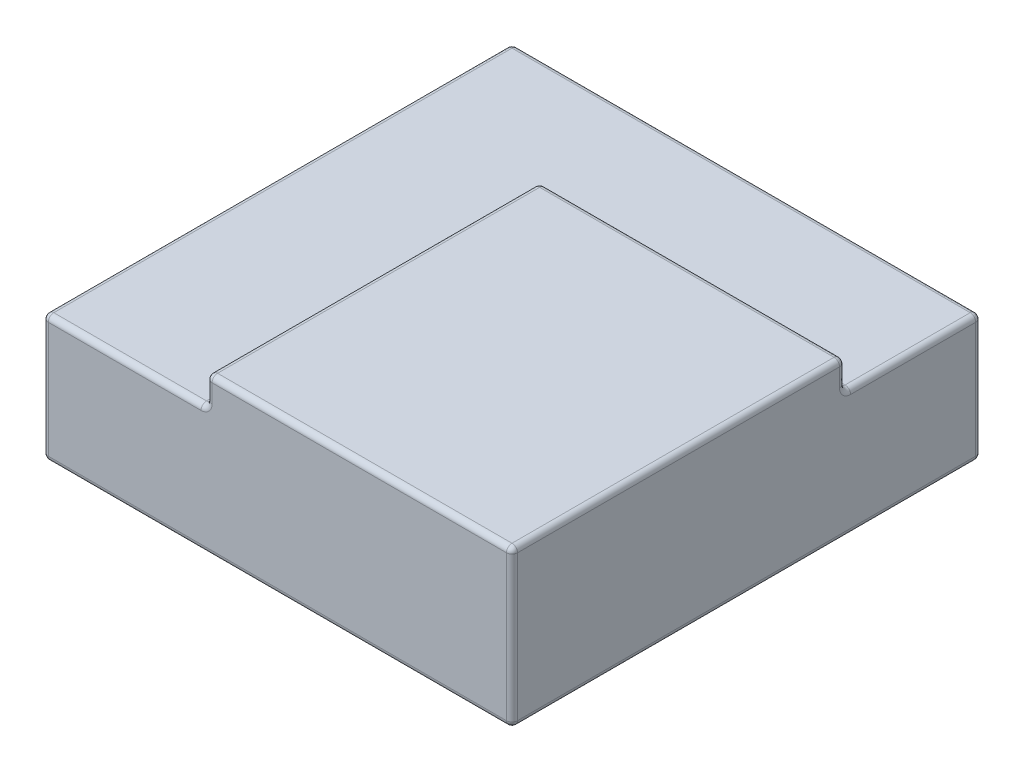
from build123d import *

# Parameters (mm, degrees)
SKETCH1_W           = 64.77
SKETCH1_H           = 64.77
BOSS_EXTRUDE1_DEPTH = 21.59
SKETCH2_OUTSIDE_W   = 85.592
SKETCH2_OUTSIDE_H   = 85.592
SKETCH2_OUTSIDE_W_2 = 42.164
SKETCH2_OUTSIDE_H_2 = 45.974
CUT_EXTRUDE1_DEPTH  = 4.064
FILLET2_R           = 0.762


with BuildPart() as part:
    # Sketch1 → Boss-Extrude1 (new body)
    with BuildSketch(Plane(origin=(0, 0, 0), x_dir=(1, 0, 0), z_dir=(0, 1, 0))):
        Rectangle(SKETCH1_W, SKETCH1_H)
    extrude(amount=BOSS_EXTRUDE1_DEPTH)

    # Sketch2 outside → Cut-Extrude1 (cut)
    with BuildSketch(Plane(origin=(0, 21.59, 0), x_dir=(1, 0, 0), z_dir=(0, 1, 0))):
        Rectangle(SKETCH2_OUTSIDE_W, SKETCH2_OUTSIDE_H)
        with Locations((11.303, -9.398)):
            Rectangle(SKETCH2_OUTSIDE_W_2, SKETCH2_OUTSIDE_H_2, mode=Mode.SUBTRACT)
    extrude(amount=-CUT_EXTRUDE1_DEPTH, mode=Mode.SUBTRACT)

    # Fillet2
    fillet2_edges = [part.edges().sort_by_distance(p)[0] for p in [
        (11.303, 21.59, 32.385),
        (-32.385, 8.763, 32.385),
        (-21.082, 17.526, 32.385),
        (-32.385, 8.763, -32.385),
        (32.385, 8.763, -32.385),
        (11.303, 17.526, -13.589),
        (-9.779, 17.526, 9.398),
        (32.385, 17.526, -22.987),
        (0, 17.526, -32.385),
        (-32.385, 17.526, 0),
        (-9.779, 19.558, 32.385),
        (-9.779, 21.59, 9.398),
        (-9.779, 19.558, -13.589),
        (11.303, 21.59, -13.589),
        (32.385, 19.558, -13.589),
        (32.385, 21.59, 9.398),
        (0, 0, 32.385),
        (-32.385, 0, 0),
        (0, 0, -32.385),
        (32.385, 0, 0),
        (32.385, 10.795, 32.385),
    ]]
    fillet(fillet2_edges, radius=FILLET2_R)


solid = part.part
